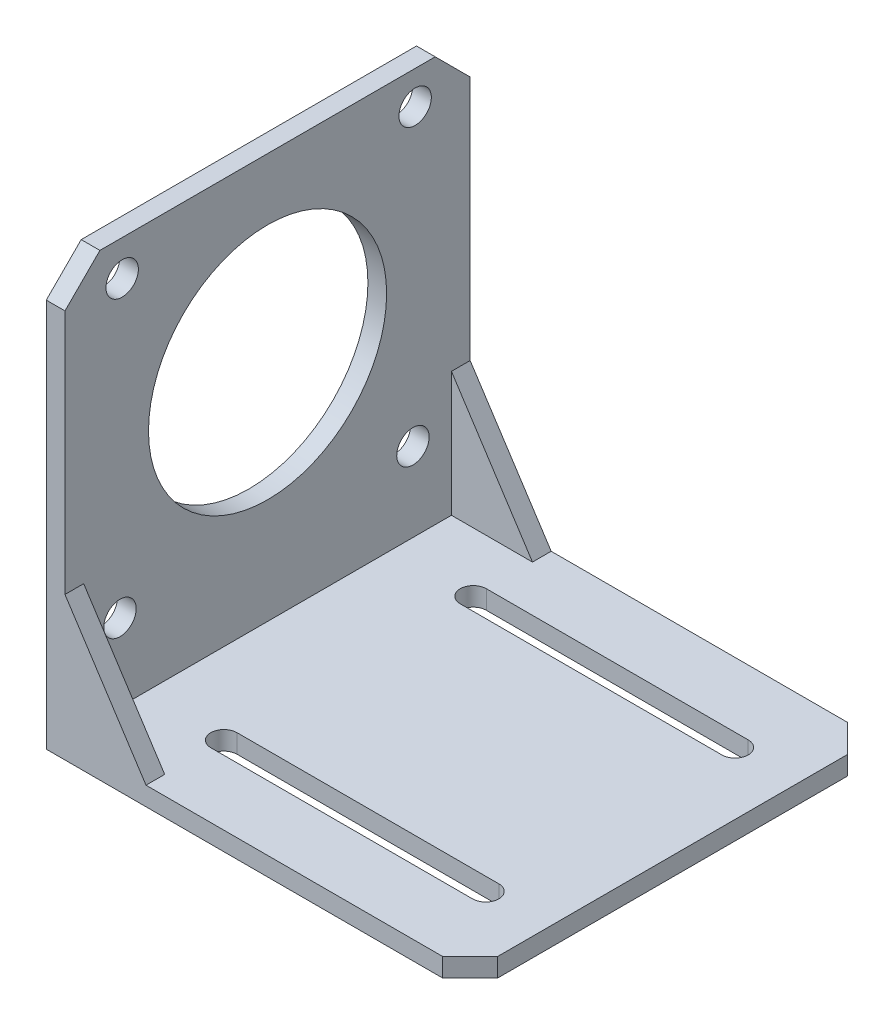
from build123d import *

# Parameters (mm, degrees)
SKETCH1_W           = 68
SKETCH1_H           = 65
BOSS_EXTRUDE1_DEPTH = 68
CUT_EXTRUDE1_DEPTH  = 66
SKETCH3_W           = 59
SKETCH3_H           = 20
CUT_EXTRUDE2_DEPTH  = 65
SKETCH4_R           = 19.1
SKETCH4_R_2         = 2.6
CUT_EXTRUDE3_DEPTH  = 4
CUT_EXTRUDE4_DEPTH  = 4


with BuildPart() as part:
    # Sketch1 → Boss-Extrude1 (new body)
    with BuildSketch(Plane(origin=(0, 0, 0), x_dir=(1, 0, 0), z_dir=(0, 1, 0))):
        with Locations((34, 32.5)):
            Rectangle(SKETCH1_W, SKETCH1_H)
    extrude(amount=BOSS_EXTRUDE1_DEPTH)

    # Sketch2 → Cut-Extrude1 (cut, through all)
    with BuildSketch(Plane.XY):
        Polygon((68, 68), (3, 68), (3, 23), (16, 3), (68, 3), align=None)
    extrude(amount=-CUT_EXTRUDE1_DEPTH, mode=Mode.SUBTRACT)

    # Sketch3 → Cut-Extrude2 (cut)
    with BuildSketch(Plane(origin=(68, 0, 0), x_dir=(0, 0, -1), z_dir=(1, 0, 0))):
        with Locations((32.5, 13)):
            Rectangle(SKETCH3_W, SKETCH3_H)
    extrude(amount=-CUT_EXTRUDE2_DEPTH, mode=Mode.SUBTRACT)

    # Sketch4 → Cut-Extrude3 (cut, through all)
    with BuildSketch(Plane(origin=(3, 0, 0), x_dir=(0, 0, -1), z_dir=(1, 0, 0))):
        Polygon((0, 68), (0, 62.395835051), (5.604164949, 68), align=None)
        Polygon((65, 68), (59.395835051, 68), (65, 62.395835051), align=None)
        with Locations((32.5, 39)):
            Circle(SKETCH4_R)
        with Locations((55.822217793, 15.677782207)):
            Circle(SKETCH4_R_2)
        with Locations((56.176447309, 62.676447309)):
            Circle(SKETCH4_R_2)
        with Locations((9.177782207, 62.322217793)):
            Circle(SKETCH4_R_2)
        with Locations((8.823552691, 15.323552691)):
            Circle(SKETCH4_R_2)
    extrude(amount=-CUT_EXTRUDE3_DEPTH, mode=Mode.SUBTRACT)

    # Sketch5 → Cut-Extrude4 (cut, through all)
    with BuildSketch(Plane(origin=(0, 3, 0), x_dir=(1, 0, 0), z_dir=(0, 1, 0))):
        with BuildLine():
            Line((58, 54.6), (16, 54.6))
            ThreePointArc((16, 54.6), (13.9, 52.5), (16, 50.4))
            Line((16, 50.4), (58, 50.4))
            ThreePointArc((58, 50.4), (60.1, 52.5), (58, 54.6))
        make_face()
        Polygon((68, 65), (63.573477358, 65), (68, 60.573477358), align=None)
        Polygon((68, 4.426522642), (63.573477358, 0), (68, 0), align=None)
        with BuildLine():
            Line((16, 10.4), (58, 10.4))
            ThreePointArc((58, 10.4), (60.1, 12.5), (58, 14.6))
            Line((58, 14.6), (16, 14.6))
            ThreePointArc((16, 14.6), (13.9, 12.5), (16, 10.4))
        make_face()
    extrude(amount=-CUT_EXTRUDE4_DEPTH, mode=Mode.SUBTRACT)


solid = part.part
